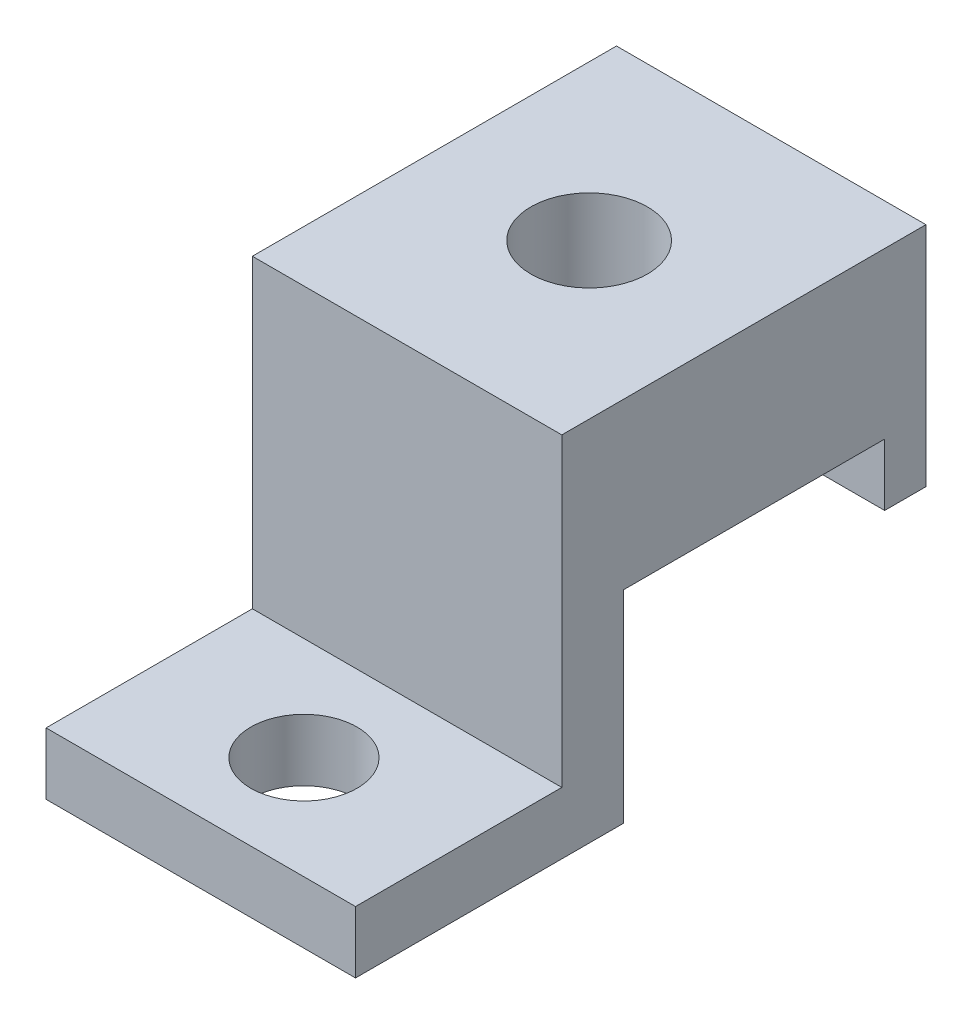
from build123d import *

# Parameters (mm, degrees)
SALIENTE_EXTRUIR1_DEPTH = 15
CROQUIS4_W              = 2
CROQUIS4_H              = 6
SALIENTE_EXTRUIR2_DEPTH = 15
CROQUIS5_R              = 2.575
CORTAR_EXTRUIR1_DEPTH   = 4
CROQUIS6_W              = 17.65
CROQUIS6_H              = 5
SALIENTE_EXTRUIR3_DEPTH = 15
CROQUIS7_R              = 2.825
CORTAR_EXTRUIR2_DEPTH   = 5
CROQUIS8_R              = 1.75
CORTAR_EXTRUIR3_DEPTH   = 13.8


with BuildPart() as part:
    # Croquis2 → Saliente-Extruir1 (new body)
    with BuildSketch(Plane(origin=(0, 0, 0), x_dir=(0, 0, -1), z_dir=(1, 0, 0))):
        Polygon((0, 0), (13, 0), (13, 9.8), (25.65, 9.8), (25.65, 12.8), (10, 12.8), (10, 3), (0, 3), align=None)
    extrude(amount=SALIENTE_EXTRUIR1_DEPTH)

    # Croquis4 → Saliente-Extruir2 (add, through all)
    with BuildSketch(Plane(origin=(0, 0, 0), x_dir=(0, 0, -1), z_dir=(1, 0, 0))):
        with Locations((26.65, 9.8)):
            Rectangle(CROQUIS4_W, CROQUIS4_H)
    extrude(amount=SALIENTE_EXTRUIR2_DEPTH)

    # Croquis5 → Cortar-Extruir1 (cut, through all)
    with BuildSketch(Plane(origin=(0, 3, 0), x_dir=(1, 0, 0), z_dir=(0, 1, 0))):
        with Locations((7.5, 5)):
            Circle(CROQUIS5_R)
    extrude(amount=-CORTAR_EXTRUIR1_DEPTH, mode=Mode.SUBTRACT)

    # Croquis6 → Saliente-Extruir3 (add)
    with BuildSketch(Plane(origin=(15, 0, 0), x_dir=(0, 0, -1), z_dir=(1, 0, 0))):
        with Locations((18.825, 15.3)):
            Rectangle(CROQUIS6_W, CROQUIS6_H)
    extrude(amount=-SALIENTE_EXTRUIR3_DEPTH)

    # Croquis7 → Cortar-Extruir2 (cut)
    with BuildSketch(Plane(origin=(0, 17.8, 0), x_dir=(1, 0, 0), z_dir=(0, 1, 0))):
        with Locations((7.5, 18.825)):
            Circle(CROQUIS7_R)
    extrude(amount=-CORTAR_EXTRUIR2_DEPTH, mode=Mode.SUBTRACT)

    # Croquis8 → Cortar-Extruir3 (cut, through all)
    with BuildSketch(Plane(origin=(0, 12.8, 0), x_dir=(1, 0, 0), z_dir=(0, 1, 0))):
        with Locations((7.5, 18.825)):
            Circle(CROQUIS8_R)
    extrude(amount=-CORTAR_EXTRUIR3_DEPTH, mode=Mode.SUBTRACT)


solid = part.part
